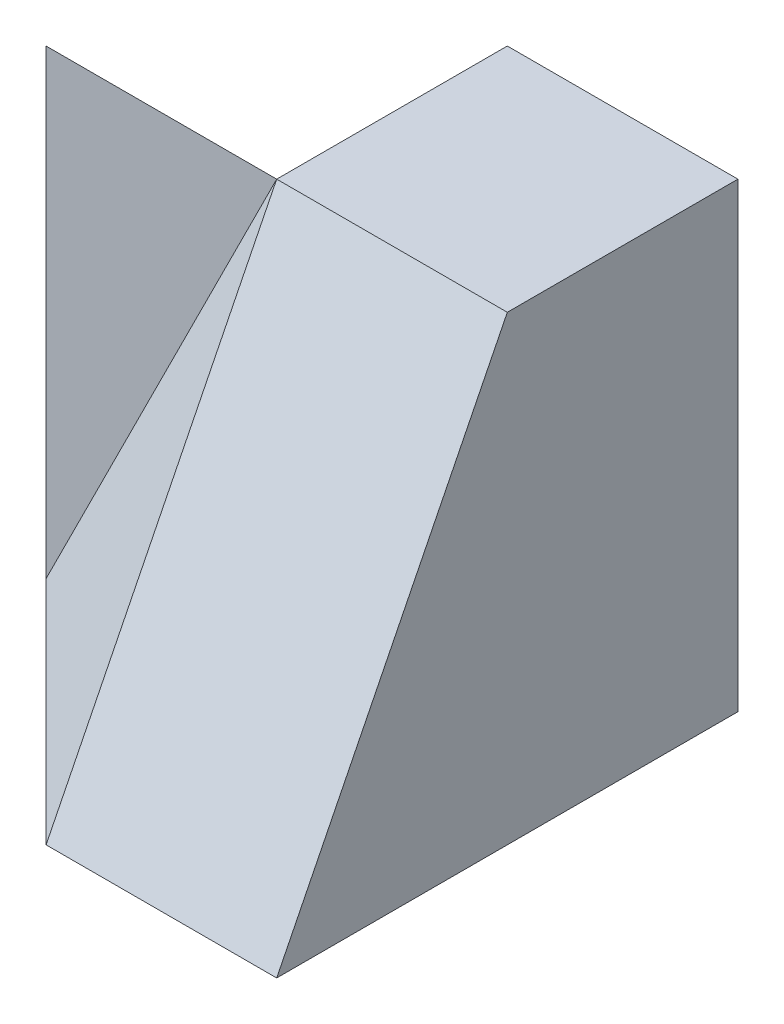
from build123d import *

# Parameters (mm, degrees)
SKETCH1_W           = 40
SKETCH1_H           = 40
BOSS_EXTRUDE1_DEPTH = 40
CUT_EXTRUDE1_DEPTH  = 40
CUT_EXTRUDE2_DEPTH  = 40
CUT_EXTRUDE3_DEPTH  = 20
CUT_EXTRUDE4_DEPTH  = 20
CUT_EXTRUDE7_DEPTH  = 49


with BuildPart() as part:
    # Sketch1 → Boss-Extrude1 (new body)
    with BuildSketch(Plane.XY):
        with Locations((20, 20)):
            Rectangle(SKETCH1_W, SKETCH1_H)
    extrude(amount=BOSS_EXTRUDE1_DEPTH)

    # Sketch2 → Cut-Extrude1 (cut)
    with BuildSketch(Plane.ZY):
        Polygon((40, 0), (20, 40), (40, 40), align=None)
    extrude(amount=-CUT_EXTRUDE1_DEPTH, mode=Mode.SUBTRACT)

    # Sketch3 → Cut-Extrude2 (cut)
    with BuildSketch(Plane.XZ):
        Polygon((0, 20), (20, 40), (0, 40), align=None)
    extrude(amount=-CUT_EXTRUDE2_DEPTH, mode=Mode.SUBTRACT)

    # Sketch4 → Cut-Extrude3 (cut)
    with BuildSketch(Plane.ZY):
        Polygon((20, 40), (0, 20), (0, 40), align=None)
    extrude(amount=-CUT_EXTRUDE3_DEPTH, mode=Mode.SUBTRACT)

    # Sketch5 → Cut-Extrude4 (cut)
    with BuildSketch(Plane(origin=(-8.888888889, 4.444444444, 8.888888889), x_dir=(0.745355992, 0.298142397, 0.596284794), z_dir=(-0.666666667, 0.333333333, 0.666666667))):
        Polygon((38.75851161, 26.83281573), (38.75851161, -17.88854382), (11.92569588, -8.94427191), align=None)
    extrude(amount=CUT_EXTRUDE4_DEPTH, mode=Mode.SUBTRACT)

    # Sketch8 → Cut-Extrude7 (cut)
    with BuildSketch(Plane.XY.offset(20)):
        Polygon((20, 40), (0, 0), (0, 40), align=None)
    extrude(amount=CUT_EXTRUDE7_DEPTH, mode=Mode.SUBTRACT)


solid = part.part
